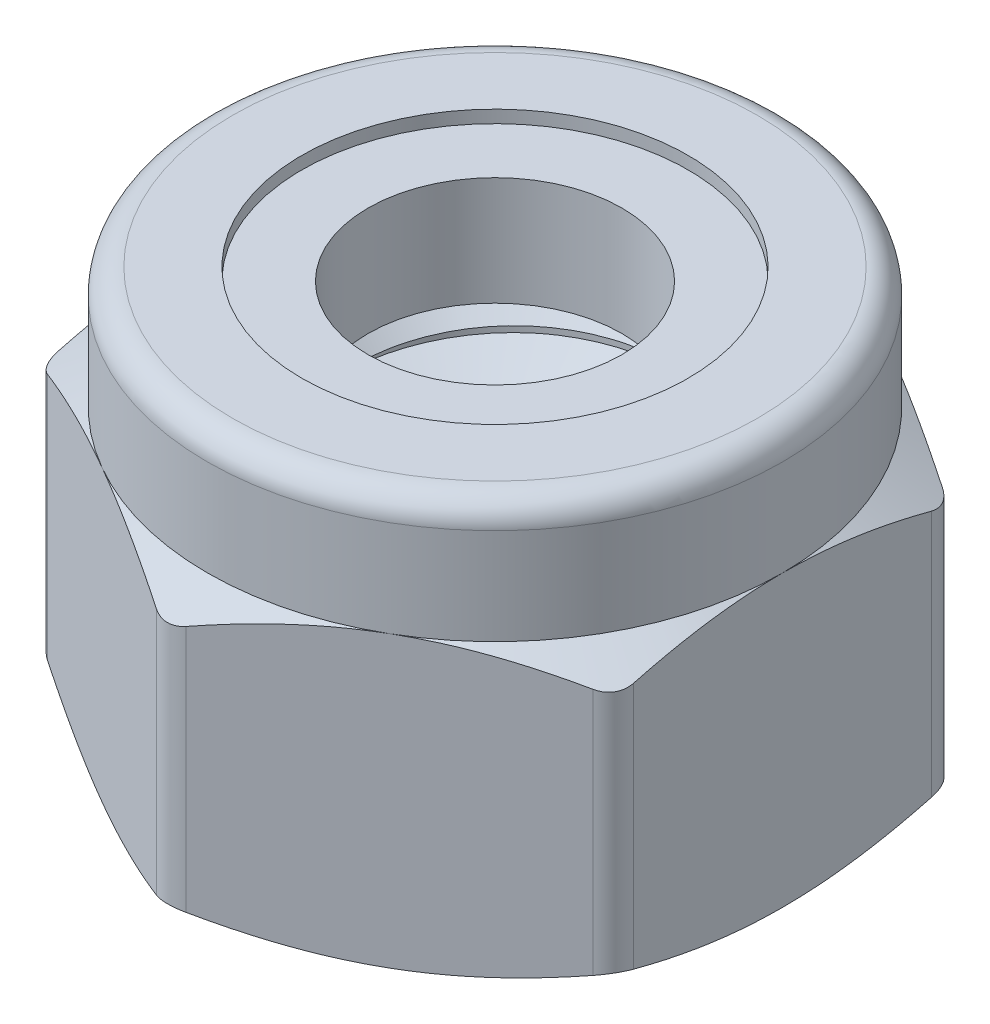
from build123d import *
from build123d.topology import SkipClean

# Parameters (mm, degrees)
BOSS_EXTRUDE1_START = 1.02418
BOSS_EXTRUDE1_DEPTH = 3.52418
FILLET1_R           = 0.36037037
SWEEP1_PITCH        = 0.7
SWEEP1_HEIGHT       = 5
SWEEP1_RADIUS       = 2
SWEEP1_START_ANGLE  = -90


with BuildPart() as part:
    # Sketch2 → Boss-Extrude1 (new body)
    with BuildSketch(Plane(origin=(0, 0, 0), x_dir=(1, 0, 0), z_dir=(0, 1, 0)).offset(BOSS_EXTRUDE1_START)):
        Polygon((3.5, 2.020725942), (0, 4.041451884), (-3.5, 2.020725942), (-3.5, -2.020725942), (0, -4.041451884), (3.5, -2.020725942), align=None)
    extrude(amount=-BOSS_EXTRUDE1_DEPTH)

    # Sketch3 → Cut-Revolve1 (revolve, cut)
    with BuildSketch(Plane.XY):
        Polygon((2, 1.890205195), (4.050555556, 0.706316393), (4.050555556, 1.890205195), align=None)
        Polygon((2, -3.366025404), (4.050555556, -2.182136602), (4.050555556, -3.366025404), align=None)
    revolve(axis=Axis((0, 2.5, 0), (0, -1, 0)), mode=Mode.SUBTRACT)

    # Fillet1
    fillet1_edges = [part.edges().sort_by_distance(p)[0] for p in [
        (-3.5, -0.737910104, -2.020725942),
        (-3.5, -0.737910104, 2.020725942),
        (0, -0.737910104, 4.041451884),
        (0, -0.737910104, -4.041451884),
        (3.5, -0.737910104, -2.020725942),
        (3.5, -0.737910104, 2.020725942),
    ]]
    fillet(fillet1_edges, radius=FILLET1_R)

    # Sketch5 → Cut-Revolve2 (revolve, cut)
    with BuildSketch(Plane.XY, mode=Mode.PRIVATE) as cut_revolve2_sk:
        Polygon((-2.35, -2.5), (-2, -2.15), (-2, 0.674179791), (-2.35, 1.024179791), (0, 1.024179791), (0, -2.5), align=None)
    revolve(cut_revolve2_sk.sketch.rotate(Axis((0, 2.5, 0), (0, -1, 0)), 270), axis=Axis((0, 2.5, 0), (0, -1, 0)), mode=Mode.SUBTRACT)

    # Sketch4 → Revolve1 (revolve)
    with BuildSketch(Plane.XY, mode=Mode.PRIVATE) as revolve1_sk:
        with BuildLine():
            Line((-2.35, 2.5), (-3.19375, 2.5))
            ThreePointArc((-3.19375, 2.5), (-3.410301452, 2.410301452), (-3.5, 2.19375))
            Line((-3.5, 2.19375), (-3.5, 1.024179791))
            Line((-3.5, 1.024179791), (-3.346875, 1.024179791))
            Line((-3.346875, 1.024179791), (-3.346875, 2.19375))
            ThreePointArc((-3.346875, 2.19375), (-3.302025726, 2.302025726), (-3.19375, 2.346875))
            Line((-3.19375, 2.346875), (-2.35, 2.346875))
            Line((-2.35, 2.346875), (-2.35, 2.5))
        make_face()
    revolve(revolve1_sk.sketch.rotate(Axis((0, 2.5, 0), (0, -1, 0)), 270), axis=Axis((0, 2.5, 0), (0, -1, 0)))

    # Sweep1: sweep along a helix
    with BuildLine() as sweep1_path:
        add(Helix(SWEEP1_PITCH, SWEEP1_HEIGHT, SWEEP1_RADIUS, center=(0, -2.5, 0), direction=(0, 1, 0), lefthand=True, mode=Mode.PRIVATE).rotate(Axis((0, -2.5, 0), (0, 1, 0)), SWEEP1_START_ANGLE))
    # Sketch8 → Sweep1 (sweep)
    with BuildSketch(Plane.XY):
        Polygon((-2.037888611, -2.478125), (-2.037888611, -3.134375), (-1.545336663, -2.85), (-1.545336663, -2.7625), align=None)
    sweep(path=sweep1_path.line, is_frenet=True)

    # Sketch9 → Cut-Revolve3 (revolve, cut)
    with SkipClean():  # the faces are left unmerged after this step: merging them gives an invalid solid
        with BuildSketch(Plane.XY, mode=Mode.PRIVATE) as cut_revolve3_sk:
            Polygon((-2.35, 2.653125), (-2.35, 1.024179791), (-1.46955944, 0.143739231), (-1.46955944, 2.653125), align=None)
            Polygon((-1.46955944, -1.61955944), (-2.35, -2.5), (-2.35, -3.15625), (-1.46955944, -3.15625), align=None)
        revolve(cut_revolve3_sk.sketch.rotate(Axis((0, 2.5, 0), (0, -1, 0)), 135.52248178), axis=Axis((0, 2.5, 0), (0, -1, 0)), mode=Mode.SUBTRACT)


with BuildPart() as body_2:
    # Sketch6 → Revolve2 (revolve)
    with BuildSketch(Plane.XY, mode=Mode.PRIVATE) as revolve2_sk:
        with BuildLine():
            Line((-3.19375, 2.346875), (-1.545336663, 2.346875))
            Line((-1.545336663, 2.346875), (-1.545336663, 1.024179791))
            Line((-1.545336663, 1.024179791), (-3.346875, 1.024179791))
            Line((-3.346875, 1.024179791), (-3.346875, 2.19375))
            ThreePointArc((-3.346875, 2.19375), (-3.302025726, 2.302025726), (-3.19375, 2.346875))
        make_face()
    revolve(revolve2_sk.sketch.rotate(Axis((0, 2.5, 0), (0, -1, 0)), 270), axis=Axis((0, 2.5, 0), (0, -1, 0)))


solid = Compound([part.part, body_2.part])
